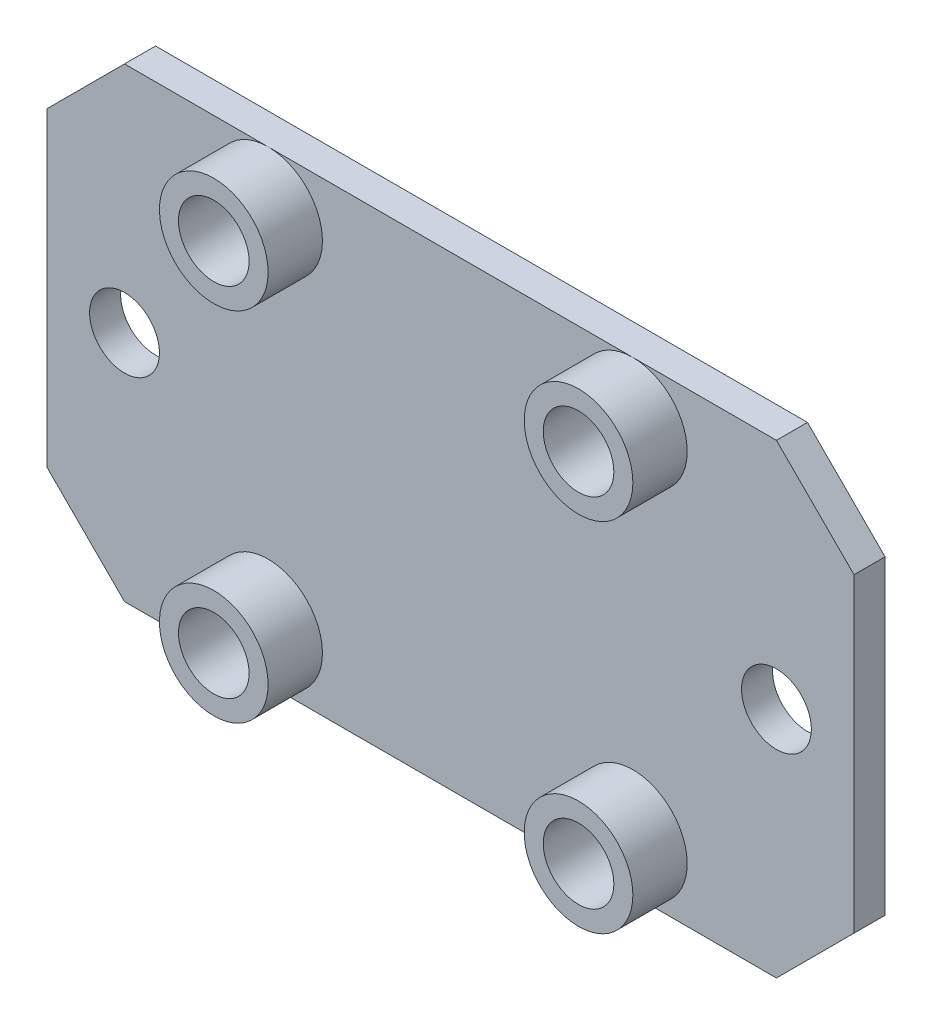
from build123d import *

# Parameters (mm, degrees)
SKETCH_1_W          = 30
SKETCH_1_H          = 52
EXTRUDE_1_DEPTH     = 2
SKETCH_2_R          = 3.5
EXTRUDE_2_DEPTH     = 3.5
SKETCH_5_R          = 2.275
CUT_EXTRUDE_1_DEPTH = 3.5
HOLE_WIZARD_M4_1_D  = 4.5
CHAMFER_1_SIZE      = 5


with BuildPart() as part:
    # ｽｹｯﾁ1 → ﾎﾞｽ - 押し出し1 (new body)
    with BuildSketch(Plane(origin=(0, 0, 0), x_dir=(0, 1, 0), z_dir=(0, 0, 1))):
        with Locations((15, 26)):
            Rectangle(SKETCH_1_W, SKETCH_1_H)
    extrude(amount=EXTRUDE_1_DEPTH)

    # ｽｹｯﾁ2 → ﾎﾞｽ - 押し出し2 (add)
    with BuildSketch(Plane.XY.offset(2)):
        with Locations((-37.75, 26.5)):
            Circle(SKETCH_2_R)
        with Locations((-14.25, 26.5)):
            Circle(SKETCH_2_R)
        with Locations((-14.25, 3.5)):
            Circle(SKETCH_2_R)
        with Locations((-37.75, 3.5)):
            Circle(SKETCH_2_R)
    extrude(amount=EXTRUDE_2_DEPTH)

    # ｽｹｯﾁ5 → ｶｯﾄ - 押し出し1 (cut)
    with BuildSketch(Plane.XY.offset(5.5)):
        with Locations((-37.75, 26.5)):
            Circle(SKETCH_5_R)
        with Locations((-14.25, 26.5)):
            Circle(SKETCH_5_R)
        with Locations((-14.25, 3.5)):
            Circle(SKETCH_5_R)
        with Locations((-37.75, 3.5)):
            Circle(SKETCH_5_R)
    extrude(amount=-CUT_EXTRUDE_1_DEPTH, mode=Mode.SUBTRACT)

    # M4 すきま穴1 (through all)
    with Locations(Plane.XY.offset(2)):
        with Locations((-47, 15), (-5, 15)):
            Hole(HOLE_WIZARD_M4_1_D / 2)

    # 面取り1
    chamfer_1_edges = [part.edges().sort_by_distance(p)[0] for p in [
        (-52, 0, 1),
        (-52, 30, 1),
        (0, 30, 1),
        (0, 0, 1),
    ]]
    chamfer(chamfer_1_edges, length=CHAMFER_1_SIZE)


solid = part.part
